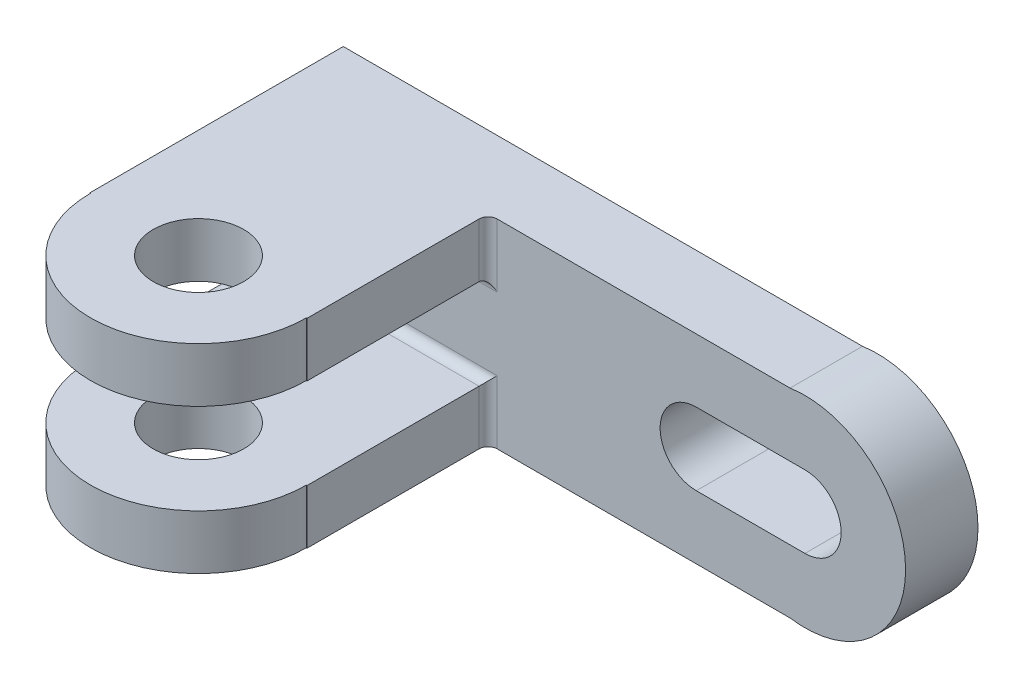
from build123d import *

# Parameters (mm, degrees)
SKETCH1_W           = 118
SKETCH1_H           = 44
BOSS_EXTRUDE1_DEPTH = 16
SKETCH2_R           = 22.242499638
BOSS_EXTRUDE2_DEPTH = 16
CUT_EXTRUDE1_DEPTH  = 17
SKETCH4_R           = 10
BOSS_EXTRUDE9_DEPTH = 12
FILLET1_R           = 2


with BuildPart() as part:
    # Sketch1 → Boss-Extrude1 (new body)
    with BuildSketch(Plane.XY):
        with Locations((17.077018634, -4.238509317)):
            Rectangle(SKETCH1_W, SKETCH1_H)
    extrude(amount=BOSS_EXTRUDE1_DEPTH)

    # Sketch2 → Boss-Extrude2 (add)
    with BuildSketch(Plane.XY.offset(16)):
        with Locations((76.077018634, -4.238509317)):
            Circle(SKETCH2_R)
    extrude(amount=-BOSS_EXTRUDE2_DEPTH)

    # Sketch3 → Cut-Extrude1 (cut, through all)
    with BuildSketch(Plane.XY.offset(16)):
        with BuildLine():
            Line((76.077018634, -12.238509317), (52.077018634, -12.238509317))
            ThreePointArc((52.077018634, -12.238509317), (44.077018634, -4.238509317), (52.077018634, 3.761490683))
            Line((52.077018634, 3.761490683), (76.077018634, 3.761490683))
            ThreePointArc((76.077018634, 3.761490683), (84.077018634, -4.238509317), (76.077018634, -12.238509317))
        make_face()
    extrude(amount=-CUT_EXTRUDE1_DEPTH, mode=Mode.SUBTRACT)

    # Sketch4 → Boss-Extrude9 (add)
    with BuildSketch(Plane.XZ.offset(26.238509317)):
        with BuildLine():
            Line((-41.922981366, 16), (-41.922981366, 56))
            Line((-41.922981366, 56), (-41.77422342, 56))
            ThreePointArc((-41.77422342, 56), (-17.922981366, 79.851242053), (5.928260687, 56))
            Line((5.928260687, 56), (6.077018634, 56))
            Line((6.077018634, 56), (6.077018634, 16))
            Line((6.077018634, 16), (-41.922981366, 16))
        make_face()
        with Locations((-17.922981366, 56)):
            Circle(SKETCH4_R, mode=Mode.SUBTRACT)
    boss_extrude9 = extrude(amount=-BOSS_EXTRUDE9_DEPTH)

    # Mirror14: Boss-Extrude9 across plane
    add(boss_extrude9.mirror(Plane.ZX.offset(-4.238509317)))

    # Fillet1
    fillet1_edges = [part.edges().sort_by_distance(p)[0] for p in [
        (6.077018634, -20.238509317, 16),
        (-17.922981366, -14.238509317, 16),
        (-17.922981366, 5.761490683, 16),
        (6.077018634, 11.761490683, 16),
    ]]
    fillet(fillet1_edges, radius=FILLET1_R)


solid = part.part
